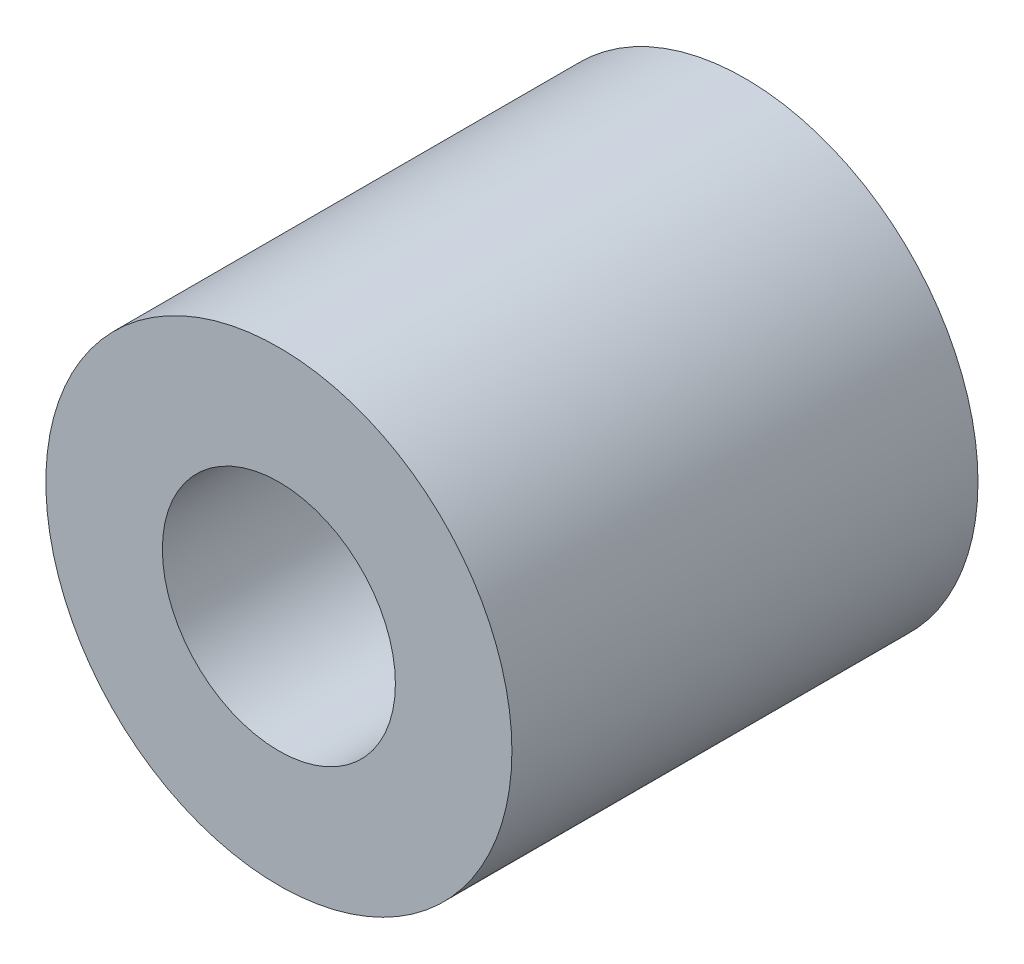
from build123d import *

# Parameters (mm, degrees)
SKETCH1_R           = 3.175
SKETCH1_R_2         = 1.5875
BOSS_EXTRUDE1_DEPTH = 6.35


with BuildPart() as part:
    # Sketch1 → Boss-Extrude1 (new body)
    with BuildSketch(Plane.XY):
        Circle(SKETCH1_R)
        Circle(SKETCH1_R_2, mode=Mode.SUBTRACT)
    extrude(amount=BOSS_EXTRUDE1_DEPTH)


solid = part.part
